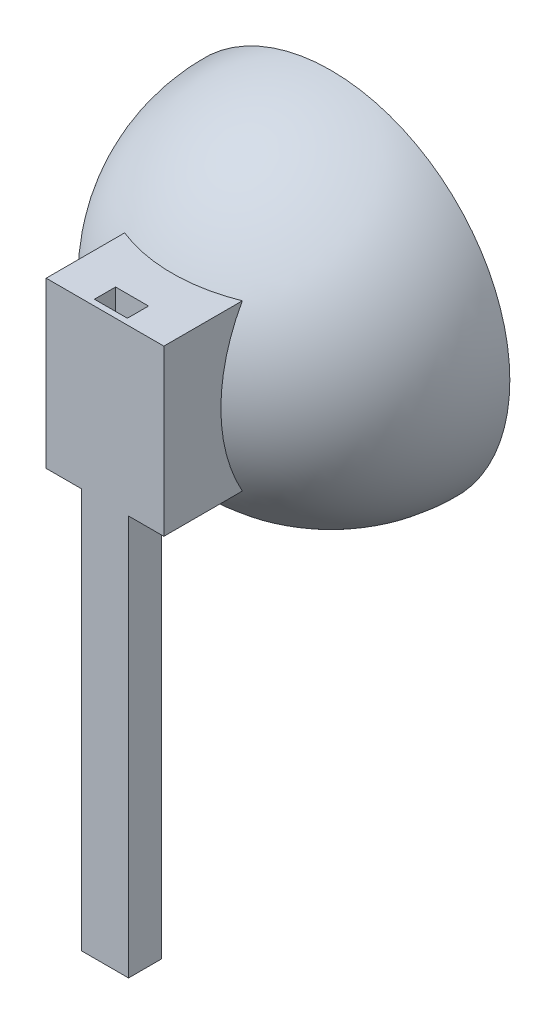
from build123d import *

# Parameters (mm, degrees)
REVOLVE1_ANGLE                  = 180
BOSS_EXTRUDE2_REACH             = 67.818
SKETCH2_W                       = 25
SKETCH2_H                       = 35
BOSS_EXTRUDE2_DIRECTION_2_DEPTH = 10
SKETCH5_W                       = 10
SKETCH5_H                       = 120
BOSS_EXTRUDE3_DEPTH             = 7
SKETCH6_W                       = 7
SKETCH6_H                       = 4.5
CUT_EXTRUDE1_DEPTH              = 265


with BuildPart() as part:
    # Sketch1 → Revolve1 (revolve)
    with BuildSketch(Plane.XY):
        with BuildLine():
            Line((0, 38), (0, 33))
            ThreePointArc((0, 33), (33, 0), (0, -33))
            Line((0, -33), (0, -38))
            ThreePointArc((0, -38), (38, 0), (0, 38))
        make_face()
    revolve(axis=Axis((0, -33, 0), (0, -1, 0)), revolution_arc=REVOLVE1_ANGLE)

    # Sketch2 → Boss-Extrude2 (add, up to next)
    with BuildSketch(Plane(origin=(0, 0, 38), x_dir=(-1, 0, 0), z_dir=(0, 0, -1)), mode=Mode.PRIVATE) as boss_extrude2_sk1:
        Rectangle(SKETCH2_W, SKETCH2_H)
    boss_extrude2_tool1 = extrude(boss_extrude2_sk1.sketch, amount=BOSS_EXTRUDE2_REACH, mode=Mode.PRIVATE) - part.part
    add(boss_extrude2_tool1.solids().sort_by_distance((0, 0, 38))[0])

    # Sketch2 → Boss-Extrude2 direction 2 (add)
    with BuildSketch(Plane(origin=(0, 0, 38), x_dir=(-1, 0, 0), z_dir=(0, 0, -1))):
        Rectangle(SKETCH2_W, SKETCH2_H)
    extrude(amount=-BOSS_EXTRUDE2_DIRECTION_2_DEPTH)

    # Sketch5 → Boss-Extrude3 (add)
    with BuildSketch(Plane.XY.offset(48)):
        with Locations((0, -42.5)):
            Rectangle(SKETCH5_W, SKETCH5_H)
    extrude(amount=-BOSS_EXTRUDE3_DEPTH)

    # Sketch6 → Cut-Extrude1 (cut)
    with BuildSketch(Plane(origin=(0, -102.5, 0), x_dir=(-1, 0, 0), z_dir=(0, -1, 0))):
        with Locations((0, -44.5)):
            Rectangle(SKETCH6_W, SKETCH6_H)
    extrude(amount=-CUT_EXTRUDE1_DEPTH, mode=Mode.SUBTRACT)


solid = part.part
